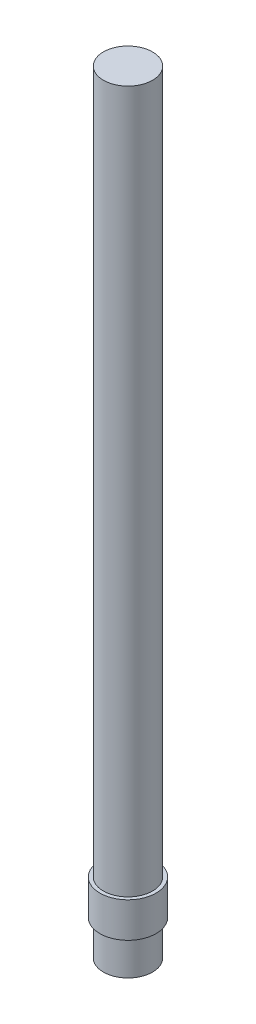
from build123d import *

# Parameters (mm, degrees)
SKETCH1_R           = 3.5
BOSS_EXTRUDE1_DEPTH = 5
SKETCH2_R           = 4
BOSS_EXTRUDE2_DEPTH = 5
SKETCH3_R           = 3.5
BOSS_EXTRUDE3_DEPTH = 100


with BuildPart() as part:
    # Sketch1 → Boss-Extrude1 (new body)
    with BuildSketch(Plane(origin=(0, 0, 0), x_dir=(1, 0, 0), z_dir=(0, 1, 0))):
        with Locations(Location((0, 0, 0), (0, 0, 270))):  # turned: the seam where the file's is
            Circle(SKETCH1_R)
    extrude(amount=BOSS_EXTRUDE1_DEPTH)

    # Sketch2 → Boss-Extrude2 (add)
    with BuildSketch(Plane(origin=(0, 5, 0), x_dir=(1, 0, 0), z_dir=(0, 1, 0))):
        with Locations(Location((0, 0, 0), (0, 0, 270))):  # turned: the seam where the file's is
            Circle(SKETCH2_R)
    extrude(amount=BOSS_EXTRUDE2_DEPTH)

    # Sketch3 → Boss-Extrude3 (add)
    with BuildSketch(Plane(origin=(0, 10, 0), x_dir=(1, 0, 0), z_dir=(0, 1, 0))):
        with Locations(Location((0, 0, 0), (0, 0, 270))):  # turned: the seam where the file's is
            Circle(SKETCH3_R)
    extrude(amount=BOSS_EXTRUDE3_DEPTH)


solid = part.part
